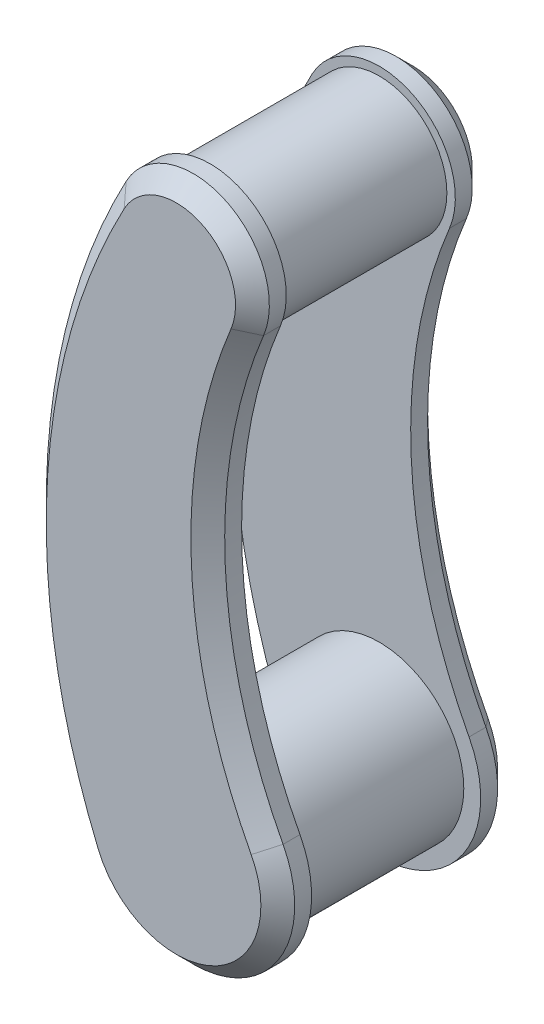
from build123d import *

# Parameters (mm, degrees)
BOSS_EXTRUDE1_DEPTH = 10
CHAMFER2_SIZE       = 5
SKETCH4_R           = 20
SKETCH4_R_2         = 25
BOSS_EXTRUDE2_DEPTH = 30


with BuildPart() as part:
    # Sketch2 → Boss-Extrude1 (new body)
    with BuildSketch(Plane.XY.offset(25)):
        with BuildLine():
            ThreePointArc((20.777841167, 66.366847826), (9.632079925, 95.3340364), (-19.842240524, 85.608274648))
            ThreePointArc((-19.842240524, 85.608274648), (-43.263152194, 0.334990999), (-27.623511317, -86.702205882))
            ThreePointArc((-27.623511317, -86.702205882), (12.846707304, -102.110184644), (26.549463713, -61.03125))
            ThreePointArc((26.549463713, -61.03125), (9.450478546, 2.023887612), (20.777841167, 66.366847826))
        make_face()
    extrude(amount=BOSS_EXTRUDE1_DEPTH)

    # Chamfer2
    chamfer2_edges = [part.edges().sort_by_distance(p)[0] for p in [
        (9.450478546, 2.023887612, 35),
        (9.632079925, 95.3340364, 35),
        (-43.263152194, 0.334990999, 35),
        (12.846707304, -102.110184644, 35),
    ]]
    chamfer(chamfer2_edges, length=CHAMFER2_SIZE)

    # Sketch4 → Boss-Extrude2 (add)
    with BuildSketch(Plane(origin=(0, 0, 25), x_dir=(-1, 0, 0), z_dir=(0, 0, -1))):
        with Locations((0, 75)):
            Circle(SKETCH4_R)
        with Locations((0, -75)):
            Circle(SKETCH4_R_2)
    extrude(amount=BOSS_EXTRUDE2_DEPTH)

    # Mirror3: part across plane


with BuildPart() as part_1:
    add(part.part)
    add(part.part.mirror(Plane.XY))


solid = part_1.part
